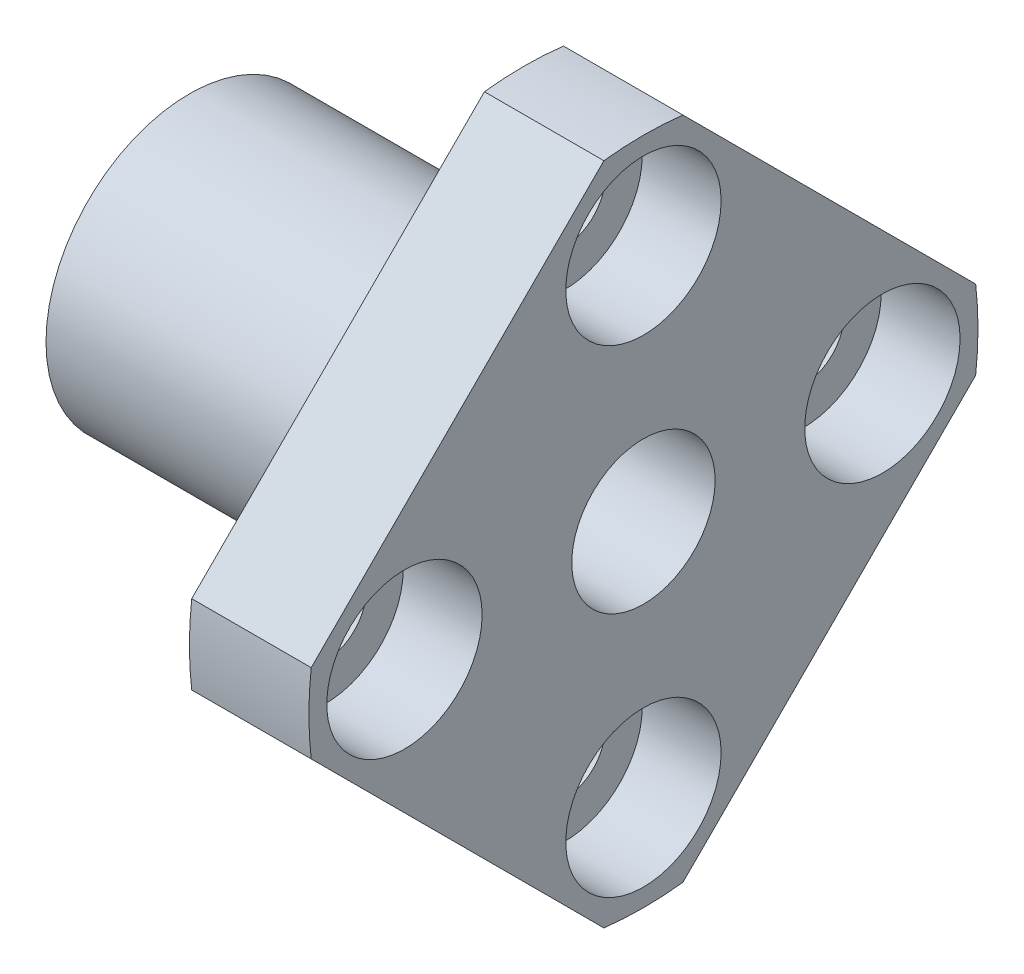
from build123d import *

# Parameters (mm, degrees)
BOSS_EXTRUDE1_DEPTH                              = 5
SKETCH2_W                                        = 14
SKETCH2_H                                        = 6
F_6_0_6_DIAMETER_HOLE1_D                         = 6
F_6_0_6_DIAMETER_HOLE1_DEPTH                     = 19
CBORE_FOR_M3_HEX_HEAD_MACHINE_SCREW1_D           = 3.4
CBORE_FOR_M3_HEX_HEAD_MACHINE_SCREW1_DEPTH       = 19
CBORE_FOR_M3_HEX_HEAD_MACHINE_SCREW1_CBORE_D     = 6.5
CBORE_FOR_M3_HEX_HEAD_MACHINE_SCREW1_CBORE_DEPTH = 3.3


with BuildPart() as part:
    # Sketch1 → Boss-Extrude1 (new body)
    with BuildSketch(Plane(origin=(14, 0, 0), x_dir=(0, -1, 0), z_dir=(-1, 0, 0))):
        with BuildLine():
            Line((-1.654450236, 13.90189895), (-13.90189895, 1.654450236))
            ThreePointArc((-13.90189895, 1.654450236), (-14, 0), (-13.90189895, -1.654450236))
            Line((-13.90189895, -1.654450236), (-1.654450236, -13.90189895))
            ThreePointArc((-1.654450236, -13.90189895), (0, -14), (1.654450236, -13.90189895))
            Line((1.654450236, -13.90189895), (13.90189895, -1.654450236))
            ThreePointArc((13.90189895, -1.654450236), (14, 0), (13.90189895, 1.654450236))
            Line((13.90189895, 1.654450236), (1.654450236, 13.90189895))
            ThreePointArc((1.654450236, 13.90189895), (0, 14), (-1.654450236, 13.90189895))
        make_face()
    extrude(amount=-BOSS_EXTRUDE1_DEPTH)

    # Sketch2 → Revolve1 (revolve)
    with BuildSketch(Plane(origin=(0, 0, 0), x_dir=(-1, 0, 0), z_dir=(0, 0, -1))):
        with Locations((-7, 3)):
            Rectangle(SKETCH2_W, SKETCH2_H)
    revolve(axis=Axis((14, 0, 0), (-1, 0, 0)))

    # Ø6.0 (6) Diameter Hole1
    with Locations(Plane(origin=(19, 0, 0), x_dir=(0, 0, -1), z_dir=(1, 0, 0))):
        with Locations((0, 0)):
            Hole(F_6_0_6_DIAMETER_HOLE1_D / 2, depth=F_6_0_6_DIAMETER_HOLE1_DEPTH)

    # CBORE for M3 Hex Head Machine Screw1
    with Locations(Plane(origin=(19, 0, 0), x_dir=(0, 0, -1), z_dir=(1, 0, 0))):
        with Locations((0, -10), (10, 0), (-10, 0), (0, 10)):
            CounterBoreHole(CBORE_FOR_M3_HEX_HEAD_MACHINE_SCREW1_D / 2, CBORE_FOR_M3_HEX_HEAD_MACHINE_SCREW1_CBORE_D / 2, CBORE_FOR_M3_HEX_HEAD_MACHINE_SCREW1_CBORE_DEPTH, depth=CBORE_FOR_M3_HEX_HEAD_MACHINE_SCREW1_DEPTH)


solid = part.part
